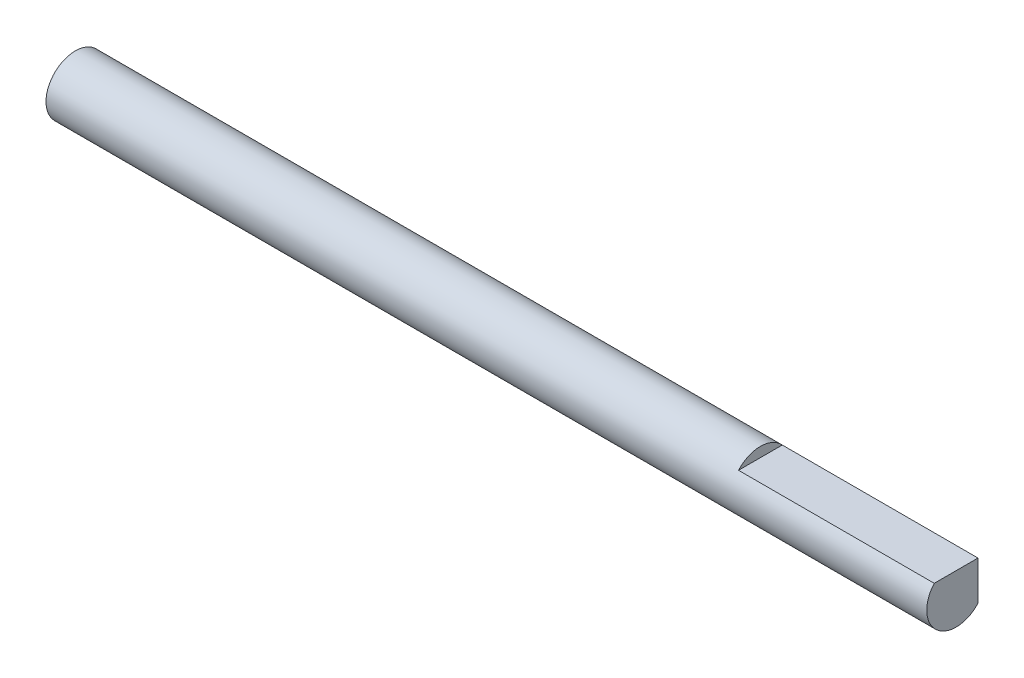
from build123d import *

# Parameters (mm, degrees)
SKETCH1_R           = 1.5
BOSS_EXTRUDE1_DEPTH = 22.5
CUT_EXTRUDE1_DEPTH  = 10
CUT_EXTRUDE2_DEPTH  = 10


with BuildPart() as part:
    # Sketch1 → Boss-Extrude1 (new body, symmetric)
    with BuildSketch(Plane(origin=(0, 0, 0), x_dir=(0, 0, -1), z_dir=(1, 0, 0))):
        Circle(SKETCH1_R)
    extrude(amount=BOSS_EXTRUDE1_DEPTH, both=True)

    # Sketch2 → Cut-Extrude1 (cut)
    with BuildSketch(Plane(origin=(22.5, 0, 0), x_dir=(0, 0, -1), z_dir=(1, 0, 0))):
        with BuildLine():
            Line((1.118033989, 1), (-1.118033989, 1))
            ThreePointArc((-1.118033989, 1), (0, 1.5), (1.118033989, 1))
        make_face()
    extrude(amount=-CUT_EXTRUDE1_DEPTH, mode=Mode.SUBTRACT)

    # Sketch3 → Cut-Extrude2 (cut)
    with BuildSketch(Plane(origin=(22.5, 0, 0), x_dir=(0, 0, -1), z_dir=(1, 0, 0))):
        with BuildLine():
            Line((1.118033989, 1), (1.118033989, -1))
            ThreePointArc((1.118033989, -1), (1.5, 0), (1.118033989, 1))
        make_face()
    extrude(amount=-CUT_EXTRUDE2_DEPTH, mode=Mode.SUBTRACT)


solid = part.part
